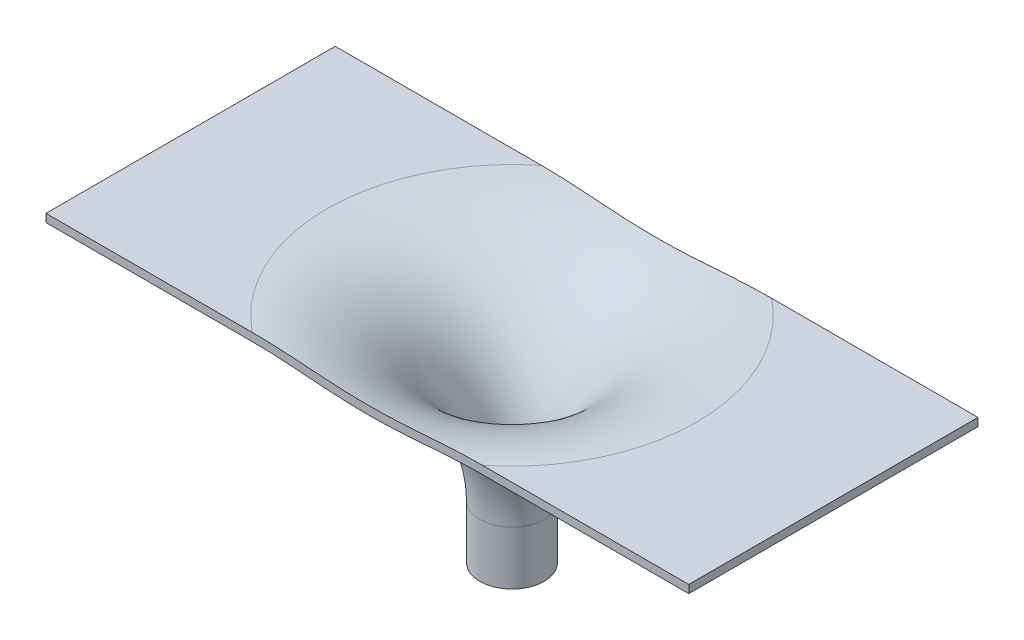
from build123d import *

# Parameters (mm, degrees)
ESQUISSE4_W             = 400
ESQUISSE4_H             = 131.578163935
ESQUISSE4_H_2           = 129.819251152
ENL_V_MAT_EXTRU_1_DEPTH = 10
BOSS_EXTRU_2_DEPTH      = 5


with BuildPart() as part:
    # Esquisse1 → Révolution3 (revolve)
    with BuildSketch(Plane(origin=(0, 0, 0), x_dir=(0, 0, -1), z_dir=(1, 0, 0))):
        with BuildLine():
            Line((-1.770428016, -67.515182568), (-1.770428016, -34.11154345))
            ThreePointArc((-1.770428016, -34.11154345), (-31.059749897, 36.599134669), (-101.770428016, 65.88845655))
            Line((-101.770428016, 65.88845655), (-186.770428016, 65.88845655))
            Line((-186.770428016, 65.88845655), (-186.770428016, 60.88845655))
            Line((-186.770428016, 60.88845655), (-101.770428016, 60.88845655))
            ThreePointArc((-101.770428016, 60.88845655), (-34.595283803, 33.063600763), (-6.770428016, -34.11154345))
            Line((-6.770428016, -34.11154345), (-6.770428016, -67.515182568))
            Line((-6.770428016, -67.515182568), (-1.770428016, -67.515182568))
        make_face()
    revolve(axis=Axis((0, -67.515182568, -13.229571984), (0, 1, 0)))

    # Esquisse4 → Enlèv. mat.-Extru.1 (cut)
    with BuildSketch(Plane(origin=(0, 65.88845655, 0), x_dir=(1, 0, 0), z_dir=(0, 1, 0))):
        with Locations((0, -142.559509983)):
            Rectangle(ESQUISSE4_W, ESQUISSE4_H)
        with Locations((0, 168.13919756)):
            Rectangle(ESQUISSE4_W, ESQUISSE4_H_2)
    extrude(amount=-ENL_V_MAT_EXTRU_1_DEPTH, mode=Mode.SUBTRACT)

    # Esquisse5 → Boss.-Extru.2 (add)
    with BuildSketch(Plane(origin=(0, 65.88845655, 0), x_dir=(1, 0, 0), z_dir=(0, 1, 0))):
        Polygon((-200, 13.229571984), (-200, 103.229571984), (-178.605710995, 103.229571984), (-178.605710995, -76.770428016), (-200, -76.770428016), align=None)
        Polygon((200, 13.229571984), (200, 103.229571984), (178.605710995, 103.229571984), (178.605710995, -76.770428016), (200, -76.770428016), align=None)
    extrude(amount=-BOSS_EXTRU_2_DEPTH)


solid = part.part
